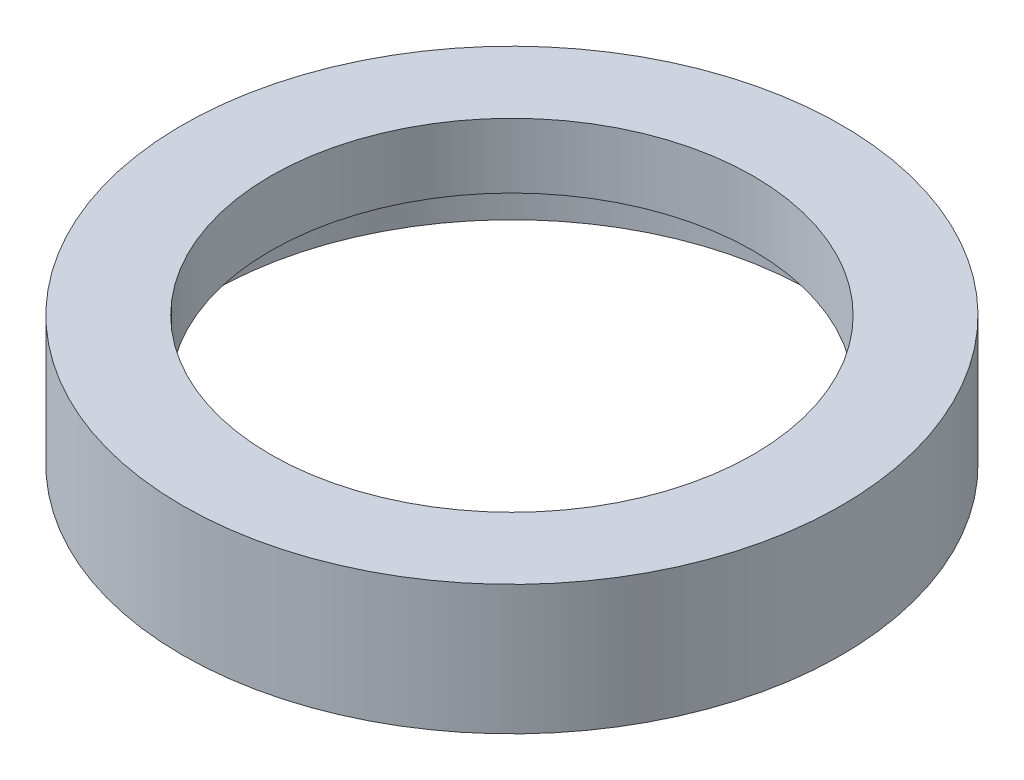
from build123d import *


with BuildPart() as part:
    # 草图1 → 旋转1 (revolve)
    with BuildSketch(Plane.XY, mode=Mode.PRIVATE) as revolve_1_sk:
        Polygon((25.5, 0), (25.5, 4.5), (26.1, 4.5), (26.1, 5.5), (20.5, 5.5), (20.5, 11), (28, 11), (28, 0), align=None)
    revolve(revolve_1_sk.sketch.rotate(Axis((0, 60.020820414, 0), (0, -1, 0)), 90), axis=Axis((0, 60.020820414, 0), (0, -1, 0)))  # turned: the seam where the file's is


solid = part.part
